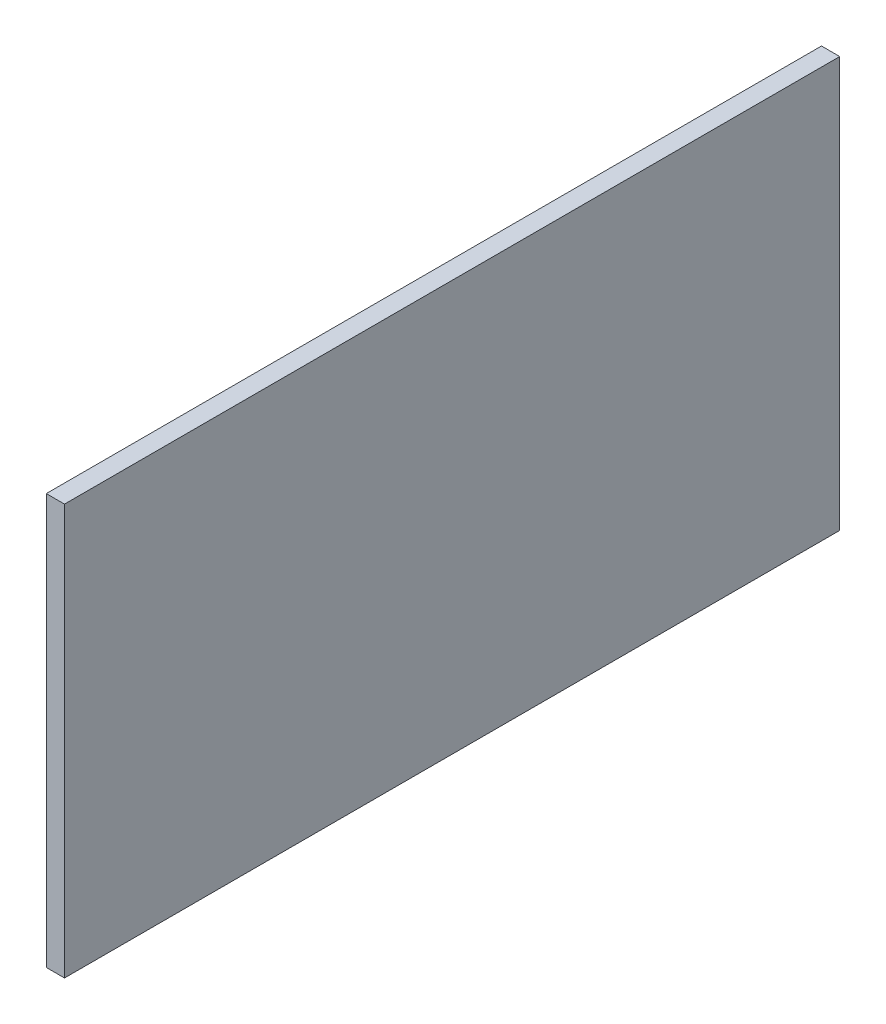
from build123d import *

# Parameters (mm, degrees)
SKETCH1_W           = 85
SKETCH1_H           = 45
BOSS_EXTRUDE1_DEPTH = 2


with BuildPart() as part:
    # Sketch1 → Boss-Extrude1 (new body)
    with BuildSketch(Plane(origin=(0, 0, 0), x_dir=(0, 0, -1), z_dir=(1, 0, 0))):
        Rectangle(SKETCH1_W, SKETCH1_H)
    extrude(amount=BOSS_EXTRUDE1_DEPTH)


solid = part.part
